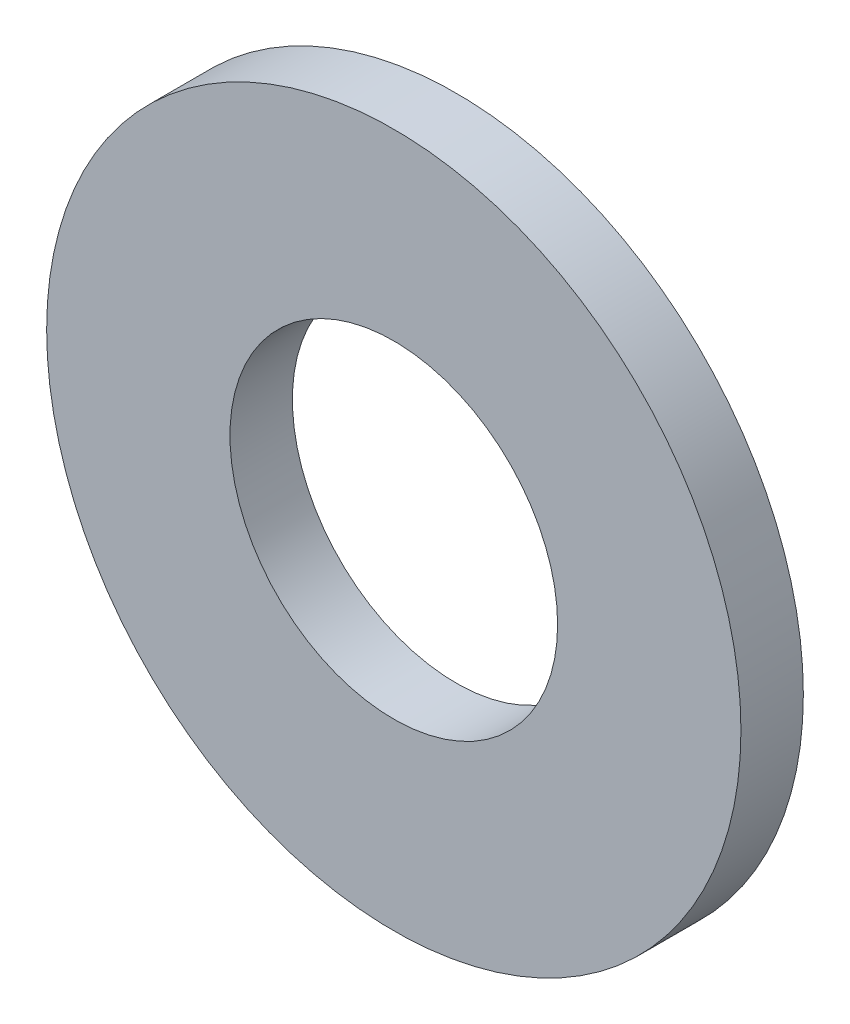
from build123d import *

# Parameters (mm, degrees)
SKETCH1_R      = 4.45
SKETCH1_R_2    = 2.1
EXTRUDE1_DEPTH = 0.8


with BuildPart() as part:
    # Sketch1 → Extrude1 (new body)
    with BuildSketch(Plane.XY):
        Circle(SKETCH1_R)
        Circle(SKETCH1_R_2, mode=Mode.SUBTRACT)
    extrude(amount=-EXTRUDE1_DEPTH)


solid = part.part
